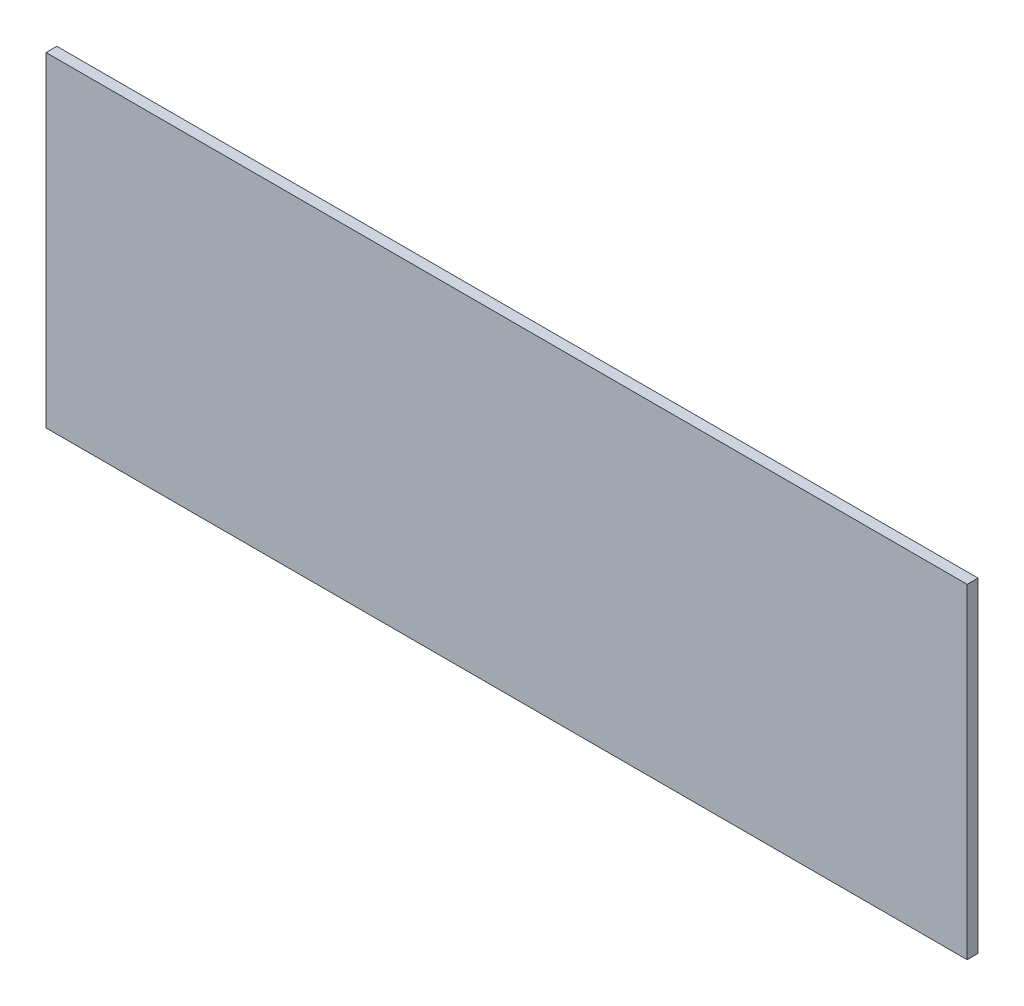
from build123d import *

# Parameters (mm, degrees)
SKETCH_1_W      = 850
SKETCH_1_H      = 300
EXTRUDE_1_DEPTH = 10


with BuildPart() as part:
    # Эскиз1 → Бобышка-Вытянуть1 (new body)
    with BuildSketch(Plane.XY):
        Rectangle(SKETCH_1_W, SKETCH_1_H)
    extrude(amount=EXTRUDE_1_DEPTH)


solid = part.part
